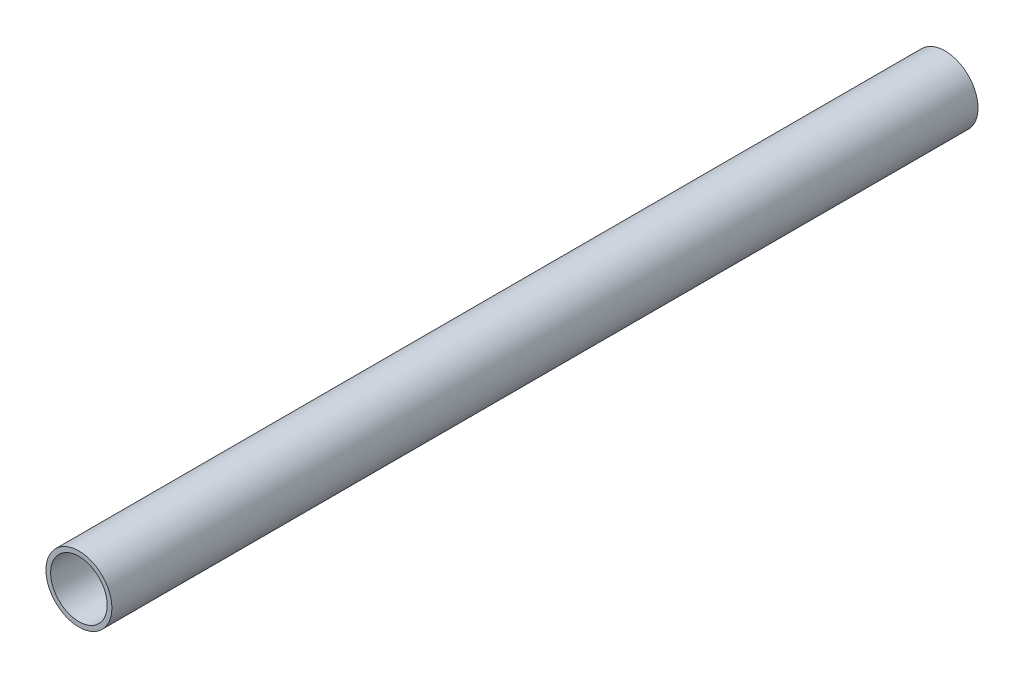
from build123d import *

# Parameters (mm, degrees)
SKETCH1_R           = 12.573
SKETCH1_R_2         = 10.795
BOSS_EXTRUDE1_DEPTH = 330.2


with BuildPart() as part:
    # Sketch1 → Boss-Extrude1 (new body)
    with BuildSketch(Plane.XY):
        Circle(SKETCH1_R)
        Circle(SKETCH1_R_2, mode=Mode.SUBTRACT)
    extrude(amount=BOSS_EXTRUDE1_DEPTH)


solid = part.part
